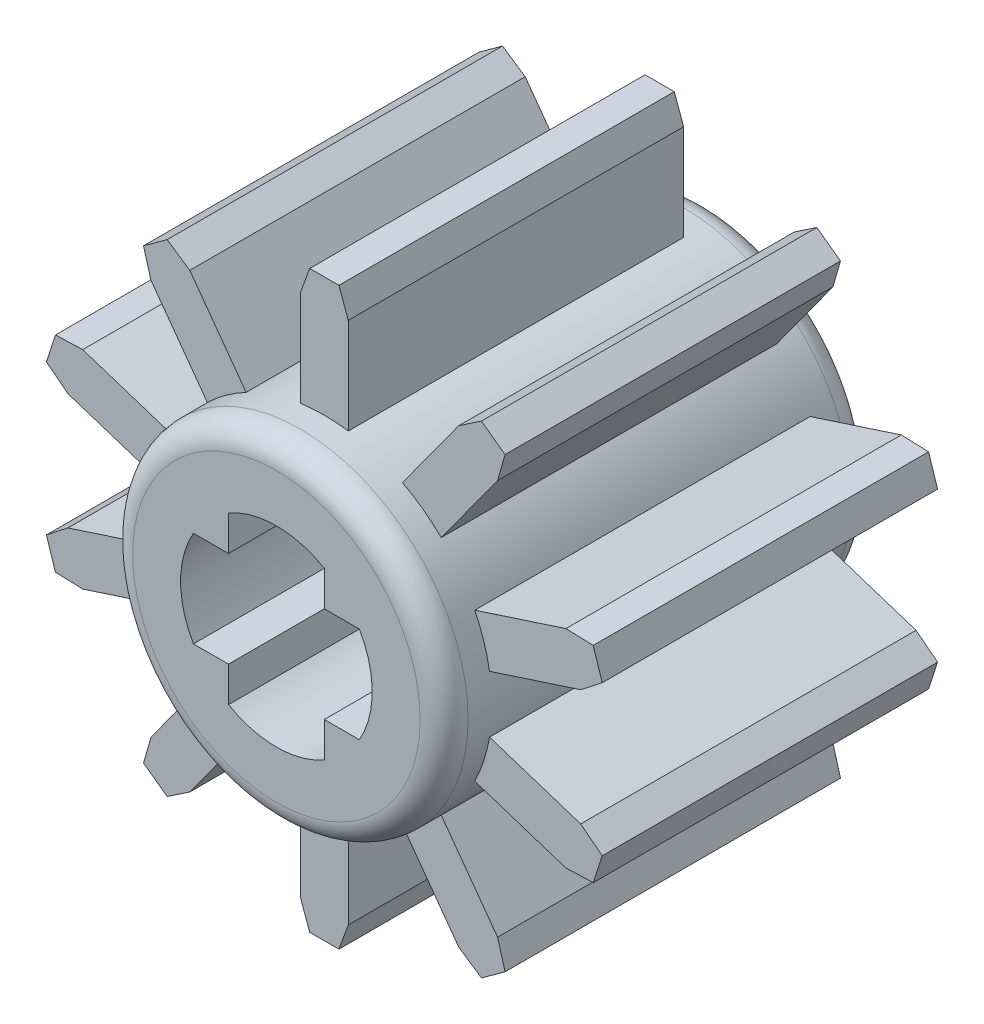
from build123d import *

# Parameters (mm, degrees)
SKETCH1_R           = 3.5
SKETCH1_R_2         = 2
BOSS_EXTRUDE1_DEPTH = 4.5
BOSS_EXTRUDE2_DEPTH = 3.5
CIRPATTERN1_COUNT   = 10
FILLET1_R           = 0.5


with BuildPart() as part:
    # Sketch1 → Boss-Extrude1 (new body, symmetric)
    with BuildSketch(Plane.XY):
        Circle(SKETCH1_R)
        Circle(SKETCH1_R_2, mode=Mode.SUBTRACT)
        with BuildLine():
            Line((1, -1), (1, -1.732050808))
            ThreePointArc((1, -1.732050808), (1.414213562, -1.414213562), (1.732050808, -1))
            Line((1.732050808, -1), (1, -1))
        make_face()
        with BuildLine():
            ThreePointArc((-1.732050808, -1), (-1.414213562, -1.414213562), (-1, -1.732050808))
            Line((-1, -1.732050808), (-1, -1))
            Line((-1, -1), (-1.732050808, -1))
        make_face()
        with BuildLine():
            Line((-1.732050808, 1), (-1, 1))
            Line((-1, 1), (-1, 1.732050808))
            ThreePointArc((-1, 1.732050808), (-1.414213562, 1.414213562), (-1.732050808, 1))
        make_face()
        with BuildLine():
            Line((1, 1.732050808), (1, 1))
            Line((1, 1), (1.732050808, 1))
            ThreePointArc((1.732050808, 1), (1.414213562, 1.414213562), (1, 1.732050808))
        make_face()
    extrude(amount=BOSS_EXTRUDE1_DEPTH, both=True)

    # Sketch2 → Boss-Extrude2 (add, symmetric)
    with BuildSketch(Plane.XY):
        with BuildLine():
            Line((-0.5, 3.464101615), (-0.5, 5.464101615))
            Line((-0.5, 5.464101615), (-0.304948939, 6))
            Line((-0.304948939, 6), (0.304948939, 6))
            Line((0.304948939, 6), (0.5, 5.464101615))
            Line((0.5, 5.464101615), (0.5, 3.464101615))
            ThreePointArc((0.5, 3.464101615), (0, 3.5), (-0.5, 3.464101615))
        make_face()
    boss_extrude2 = extrude(amount=BOSS_EXTRUDE2_DEPTH, both=True)

    # CirPattern1: Boss-Extrude2 ×10 about axis
    cirpattern1_axis = Axis((0, 0, 0), (0, 0, 1))
    for i in range(1, CIRPATTERN1_COUNT):
        add(boss_extrude2.rotate(cirpattern1_axis, i * 360 / CIRPATTERN1_COUNT))

    # Fillet1
    fillet1_edges = [part.edges().sort_by_distance(p)[0] for p in [
        (-3.5, 0, -4.5),
        (-3.5, 0, 4.5),
    ]]
    fillet(fillet1_edges, radius=FILLET1_R)


solid = part.part
